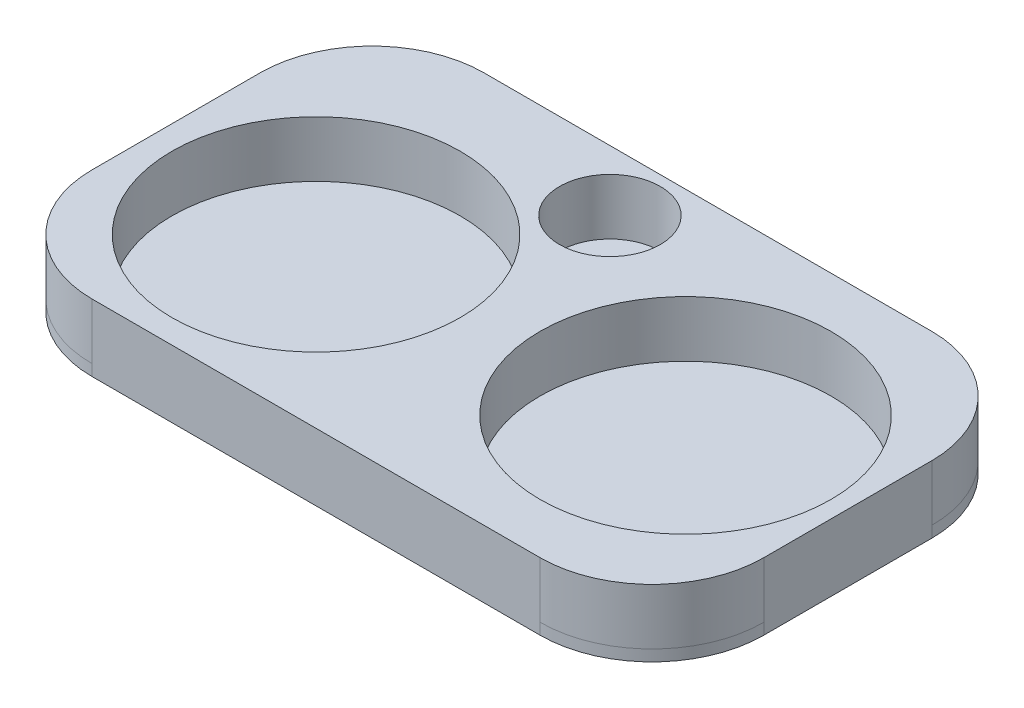
from build123d import *

# Parameters (mm, degrees)
SKETCH1_W           = 120
SKETCH1_H           = 70
SKETCH1_R           = 25.75
SKETCH1_R_2         = 9
SKETCH1_R_3         = 26
BOSS_EXTRUDE3_DEPTH = 12
FILLET1_R           = 20
SKETCH4_W           = 120
SKETCH4_H           = 70
BOSS_EXTRUDE4_DEPTH = 2
FILLET3_R           = 20


with BuildPart() as part:
    # Sketch1 → Boss-Extrude3 (new body)
    with BuildSketch(Plane(origin=(0, 0, 0), x_dir=(1, 0, 0), z_dir=(0, 1, 0))):
        with Locations((29.456172552, -29.493153194)):
            Rectangle(SKETCH1_W, SKETCH1_H)
        with Locations((-0.543827448, -34.493153194)):
            Circle(SKETCH1_R, mode=Mode.SUBTRACT)
        with Locations((22.775195688, -5.321060691)):
            Circle(SKETCH1_R_2, mode=Mode.SUBTRACT)
        with Locations((60.456172552, -29.493153194)):
            Circle(SKETCH1_R_3, mode=Mode.SUBTRACT)
    extrude(amount=BOSS_EXTRUDE3_DEPTH)

    # Fillet1
    fillet1_edges = [part.edges().sort_by_distance(p)[0] for p in [
        (-30.543827448, 6, -5.506846806),
        (89.456172552, 6, -5.506846806),
        (89.456172552, 6, 64.493153194),
        (-30.543827448, 6, 64.493153194),
    ]]
    fillet(fillet1_edges, radius=FILLET1_R)

    # Sketch4 → Boss-Extrude4 (add)
    with BuildSketch(Plane(origin=(0, 0, 0), x_dir=(1, 0, 0), z_dir=(0, 1, 0))):
        with Locations((29.456172552, -29.493153194)):
            Rectangle(SKETCH4_W, SKETCH4_H)
    extrude(amount=BOSS_EXTRUDE4_DEPTH)

    # Fillet3
    fillet3_edges = [part.edges().sort_by_distance(p)[0] for p in [
        (89.456172552, 1, -5.506846806),
        (89.456172552, 1, 64.493153194),
        (-30.543827448, 1, 64.493153194),
        (-30.543827448, 1, -5.506846806),
    ]]
    fillet(fillet3_edges, radius=FILLET3_R)


solid = part.part
